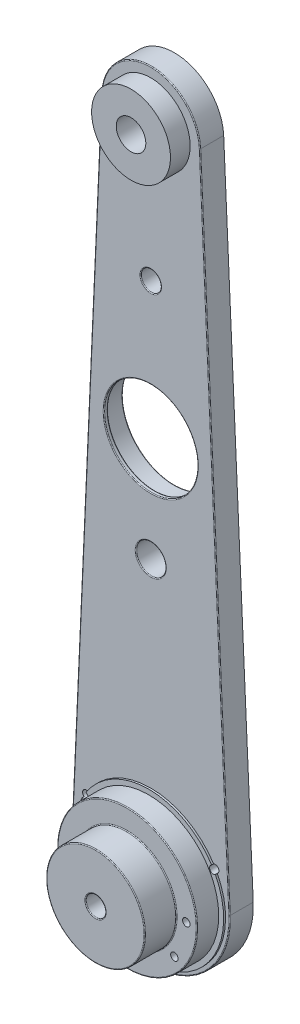
from build123d import *

# Parameters (mm, degrees)
SKETCH1_R               = 4.7625
BOSS_EXTRUDE1_DEPTH     = 3.81
SKETCH2_R               = 22.5
BOSS_EXTRUDE2_DEPTH     = 7.62
SKETCH3_R               = 24.08993992
BOSS_EXTRUDE3_DEPTH     = 0.62
SKETCH4_R               = 4.7625
SKETCH4_R_2             = 16.66875
CUT_EXTRUDE1_DEPTH      = 8.62
CUT_EXTRUDE1_DEPTH_BACK = 8.62
SKETCH6_R               = 16.66875
SKETCH6_R_2             = 15.08125
BOSS_EXTRUDE4_DEPTH     = 1.27
SKETCH7_W               = 23.5875
SKETCH7_H               = 33.75625
CUT_EXTRUDE2_DEPTH      = 2.54
SKETCH8_R               = 0.95
CUT_EXTRUDE3_DEPTH      = 13.7
SKETCH9_R               = 12.7
SKETCH9_R_2             = 4.7625
BOSS_EXTRUDE5_DEPTH     = 6.35
SKETCH10_R              = 15.875
BOSS_EXTRUDE6_DEPTH     = 10.16
SKETCH11_R              = 1.2
CUT_EXTRUDE4_DEPTH      = 1
CUT_EXTRUDE4_DEPTH_BACK = 26.4
SKETCH12_R              = 3.2385
CUT_EXTRUDE5_DEPTH      = 8.62
SKETCH13_R              = 3.175
CUT_EXTRUDE6_DEPTH      = 3.54
CUT_EXTRUDE6_DEPTH_BACK = 23.86
SKETCH14_R              = 4
CUT_EXTRUDE7_DEPTH      = 12.7
FILLET1_R               = 0.254


with BuildPart() as part:
    # Sketch1 → Boss-Extrude1 (new body, symmetric)
    with BuildSketch(Plane.XY):
        with BuildLine():
            Line((25.373713394, 1.155278592), (15.858570871, 210.139069198))
            ThreePointArc((15.858570871, 210.139069198), (0, 225.292020078), (-15.858570871, 210.139069198))
            Line((-15.858570871, 210.139069198), (-25.373713394, 1.155278592))
            ThreePointArc((-25.373713394, 1.155278592), (0, -25.4), (25.373713394, 1.155278592))
        make_face()
        with Locations((0, 209.417020078)):
            Circle(SKETCH1_R, mode=Mode.SUBTRACT)
    extrude(amount=BOSS_EXTRUDE1_DEPTH, both=True)

    # Sketch2 → Boss-Extrude2 (add)
    with BuildSketch(Plane.XY.offset(3.81)):
        Circle(SKETCH2_R)
    extrude(amount=BOSS_EXTRUDE2_DEPTH)

    # Sketch3 → Boss-Extrude3 (add)
    with BuildSketch(Plane.XY.offset(3.81)):
        Circle(SKETCH3_R)
    extrude(amount=BOSS_EXTRUDE3_DEPTH)

    # Sketch4 → Cut-Extrude1 (cut, two sides)
    with BuildSketch(Plane.XY.offset(3.81)) as cut_extrude1_sk:
        with Locations((0, 87.91702)):
            Circle(SKETCH4_R)
        with Locations((0, 121.500000078)):
            Circle(SKETCH4_R_2)
    extrude(amount=CUT_EXTRUDE1_DEPTH, mode=Mode.SUBTRACT)
    extrude(cut_extrude1_sk.sketch, amount=-CUT_EXTRUDE1_DEPTH_BACK, mode=Mode.SUBTRACT)

    # Sketch6 → Boss-Extrude4 (add)
    with BuildSketch(Plane.XY.offset(3.81)):
        with Locations((0, 121.500000078)):
            Circle(SKETCH6_R)
        with Locations((0, 121.500000078)):
            Circle(SKETCH6_R_2, mode=Mode.SUBTRACT)
    extrude(amount=-BOSS_EXTRUDE4_DEPTH)

    # Sketch7 → Cut-Extrude2 (cut)
    with BuildSketch(Plane(origin=(0, 0, -3.81), x_dir=(-1, 0, 0), z_dir=(0, 0, -1))):
        with Locations((0, -8.521875)):
            Rectangle(SKETCH7_W, SKETCH7_H)
    extrude(amount=-CUT_EXTRUDE2_DEPTH, mode=Mode.SUBTRACT)

    # Sketch8 → Cut-Extrude3 (cut, through all)
    with BuildSketch(Plane(origin=(0, 0, -1.27), x_dir=(-1, 0, 0), z_dir=(0, 0, -1))):
        with Locations((-9, 5.5625)):
            Circle(SKETCH8_R)
        with Locations((9, 5.5625)):
            Circle(SKETCH8_R)
        with Locations((9, -5.5625)):
            Circle(SKETCH8_R)
        with Locations((-9, -5.5625)):
            Circle(SKETCH8_R)
    extrude(amount=-CUT_EXTRUDE3_DEPTH, mode=Mode.SUBTRACT)

    # Sketch9 → Boss-Extrude5 (add)
    with BuildSketch(Plane.XY.offset(3.81)):
        with Locations((0, 209.417020078)):
            Circle(SKETCH9_R)
        with Locations((0, 209.417020078)):
            Circle(SKETCH9_R_2, mode=Mode.SUBTRACT)
    extrude(amount=BOSS_EXTRUDE5_DEPTH)

    # Sketch10 → Boss-Extrude6 (add)
    with BuildSketch(Plane.XY.offset(11.43)):
        Circle(SKETCH10_R)
    extrude(amount=BOSS_EXTRUDE6_DEPTH)

    # Sketch11 → Cut-Extrude4 (cut, two sides)
    with BuildSketch(Plane(origin=(0, 0, -3.81), x_dir=(-1, 0, 0), z_dir=(0, 0, -1))) as cut_extrude4_sk:
        with Locations((-20.743073922, 11.982962866)):
            Circle(SKETCH11_R)
        with Locations((20.743073922, 11.982962866)):
            Circle(SKETCH11_R)
        with Locations((19.061789704, 0)):
            Circle(SKETCH11_R)
        with Locations((15.221171432, -11.474657597)):
            Circle(SKETCH11_R)
        with Locations((-15.221171432, -11.474657597)):
            Circle(SKETCH11_R)
        with Locations((-19.061789704, 0)):
            Circle(SKETCH11_R)
    extrude(amount=CUT_EXTRUDE4_DEPTH, mode=Mode.SUBTRACT)
    extrude(cut_extrude4_sk.sketch, amount=-CUT_EXTRUDE4_DEPTH_BACK, mode=Mode.SUBTRACT)

    # Sketch12 → Cut-Extrude5 (cut, through all)
    with BuildSketch(Plane.XY.offset(3.81)):
        with Locations((0, 165.458510078)):
            Circle(SKETCH12_R)
    extrude(amount=-CUT_EXTRUDE5_DEPTH, mode=Mode.SUBTRACT)

    # Sketch13 → Cut-Extrude6 (cut, two sides)
    with BuildSketch(Plane(origin=(0, 0, -1.27), x_dir=(-1, 0, 0), z_dir=(0, 0, -1))) as cut_extrude6_sk:
        Circle(SKETCH13_R)
    extrude(amount=CUT_EXTRUDE6_DEPTH, mode=Mode.SUBTRACT)
    extrude(cut_extrude6_sk.sketch, amount=-CUT_EXTRUDE6_DEPTH_BACK, mode=Mode.SUBTRACT)

    # Sketch14 → Cut-Extrude7 (cut)
    with BuildSketch(Plane(origin=(0, 0, -1.27), x_dir=(-1, 0, 0), z_dir=(0, 0, -1))):
        Circle(SKETCH14_R)
    extrude(amount=-CUT_EXTRUDE7_DEPTH, mode=Mode.SUBTRACT)

    # Fillet1
    fillet1_edges = [part.edges().sort_by_distance(p)[0] for p in [
        (0, -25.4, 3.81),
        (-3.2385, 165.458510078, -3.81),
        (-3.2385, 165.458510078, 3.81),
        (3.175, 0, 21.59),
        (4, 0, -1.27),
        (20.616142132, 105.647173895, 3.81),
        (-22.5, 0, 11.43),
        (-4.7625, 87.91702, -3.81),
        (-4.7625, 87.91702, 3.81),
        (-16.66875, 121.500000078, -3.81),
        (-15.08125, 121.500000078, 3.81),
        (-15.08125, 121.500000078, 2.54),
        (0, 225.292020078, 3.81),
        (-20.616142132, 105.647173895, 3.81),
        (-15.875, 0, 11.43),
        (-15.875, 0, 21.59),
    ]]
    fillet(fillet1_edges, radius=FILLET1_R)


solid = part.part
